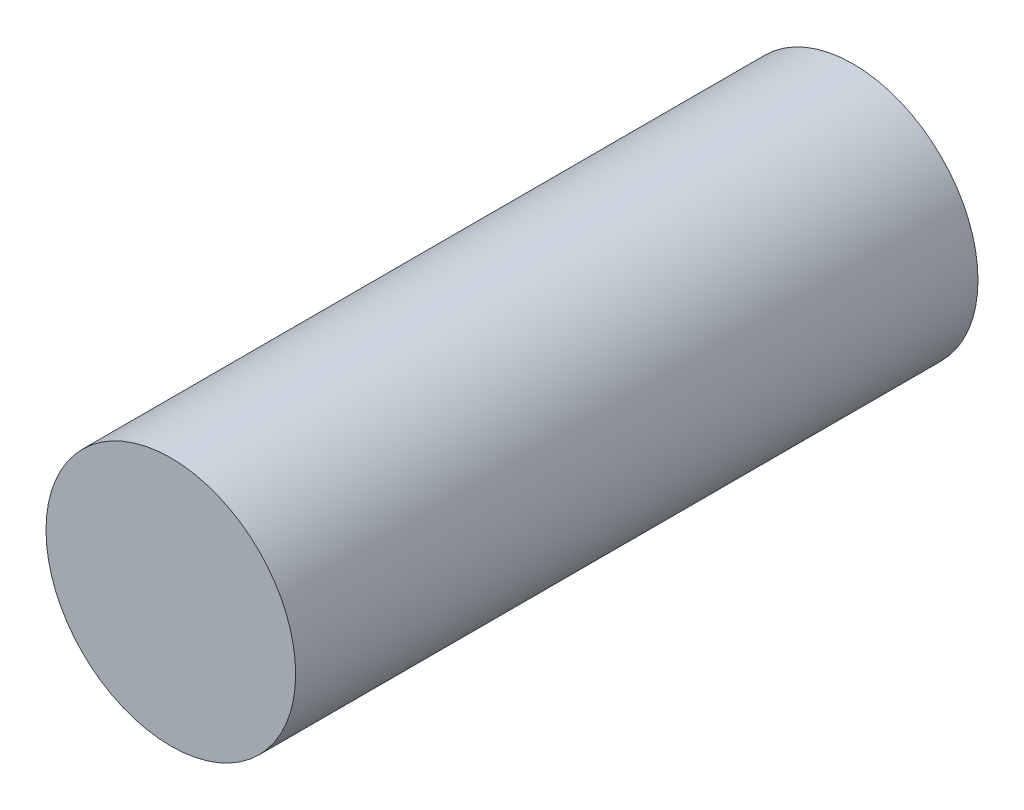
from build123d import *

# Parameters (mm, degrees)
SKETCH1_R           = 3
BOSS_EXTRUDE1_DEPTH = 16.4


with BuildPart() as part:
    # Sketch1 → Boss-Extrude1 (new body)
    with BuildSketch(Plane.XY):
        Circle(SKETCH1_R)
    extrude(amount=BOSS_EXTRUDE1_DEPTH)


solid = part.part
